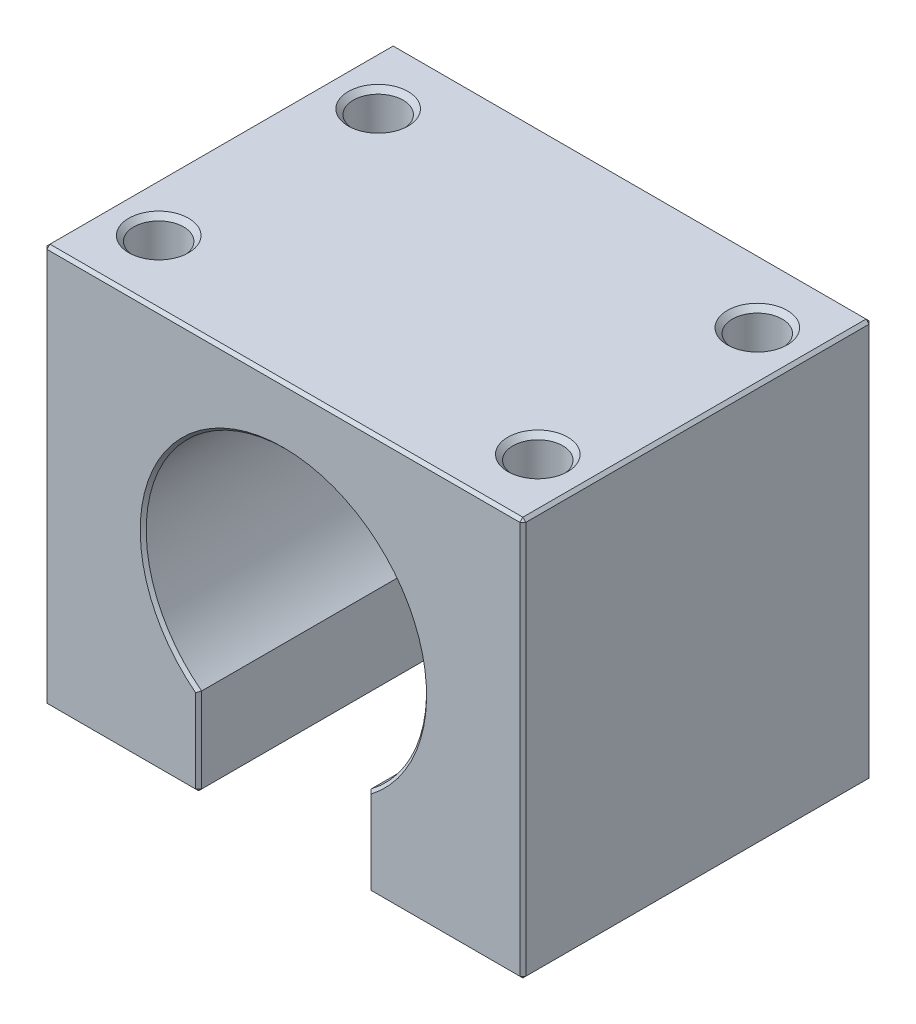
from build123d import *

# Parameters (mm, degrees)
BOSS_EXTRUDE1_DEPTH = 35
CHAMFER2_SIZE       = 0.3
SKETCH2_R           = 2.5
CUT_EXTRUDE1_DEPTH  = 17
SKETCH3_R           = 2.5
CUT_EXTRUDE2_DEPTH  = 20
CHAMFER3_SIZE       = 0.5


with BuildPart() as part:
    # Sketch1 → Boss-Extrude1 (new body)
    with BuildSketch(Plane.XY):
        with BuildLine():
            Line((24, 0), (-24, 0))
            Line((-24, 0), (-24, -40))
            Line((-24, -40), (-8.5, -40))
            Line((-8.5, -40), (-8.5, -31.187157816))
            ThreePointArc((-8.5, -31.187157816), (0, -5.95), (8.5, -31.187157816))
            Line((8.5, -31.187157816), (8.5, -40))
            Line((8.5, -40), (24, -40))
            Line((24, -40), (24, 0))
        make_face()
    extrude(amount=BOSS_EXTRUDE1_DEPTH)

    # Chamfer2
    chamfer2_edges = [part.edges().sort_by_distance(p)[0] for p in [
        (0, -5.95, 35),
        (-8.5, -35.593578908, 0),
        (-16.25, -40, 0),
        (8.5, -35.593578908, 35),
        (-24, -40, 17.5),
        (-24, 0, 17.5),
        (24, 0, 17.5),
        (24, -40, 17.5),
        (8.5, -40, 17.5),
        (-8.5, -40, 17.5),
        (16.25, -40, 35),
        (24, -20, 35),
        (0, 0, 35),
        (-24, -20, 35),
        (-16.25, -40, 35),
        (-8.5, -35.593578908, 35),
        (-24, -20, 0),
        (0, 0, 0),
        (24, -20, 0),
        (16.25, -40, 0),
        (8.5, -35.593578908, 0),
        (0, -5.95, 0),
    ]]
    chamfer(chamfer2_edges, length=CHAMFER2_SIZE)

    # Sketch2 → Cut-Extrude1 (cut)
    with BuildSketch(Plane(origin=(0, 0, 0), x_dir=(1, 0, 0), z_dir=(0, 1, 0))):
        with Locations((-19, -6.5)):
            Circle(SKETCH2_R)
        with Locations((19, -6.5)):
            Circle(SKETCH2_R)
        with Locations((19, -28.5)):
            Circle(SKETCH2_R)
        with Locations((-19, -28.5)):
            Circle(SKETCH2_R)
    extrude(amount=-CUT_EXTRUDE1_DEPTH, mode=Mode.SUBTRACT)

    # Sketch3 → Cut-Extrude2 (cut)
    with BuildSketch(Plane(origin=(0, 0, 0), x_dir=(-1, 0, 0), z_dir=(0, 0, -1))):
        with Locations((-13.435028843, -33.435028843)):
            Circle(SKETCH3_R)
        with Locations((13.435028843, -33.435028843)):
            Circle(SKETCH3_R)
        with Locations((13.435028843, -6.564971157)):
            Circle(SKETCH3_R)
        with Locations((-13.435028843, -6.564971157)):
            Circle(SKETCH3_R)
        with Locations((-19, -20)):
            Circle(SKETCH3_R)
        with Locations((19, -20)):
            Circle(SKETCH3_R)
    extrude(amount=-CUT_EXTRUDE2_DEPTH, mode=Mode.SUBTRACT)

    # Chamfer3
    chamfer3_edges = [part.edges().sort_by_distance(p)[0] for p in [
        (16.5, 0, 28.5),
        (-21.5, 0, 28.5),
        (15.935028843, -33.435028843, 0),
        (-10.935028843, -33.435028843, 0),
        (-10.935028843, -6.564971157, 0),
        (-16.5, -20, 0),
        (21.5, -20, 0),
        (-21.5, 0, 6.5),
        (16.5, 0, 6.5),
    ]]
    chamfer(chamfer3_edges, length=CHAMFER3_SIZE)


solid = part.part
